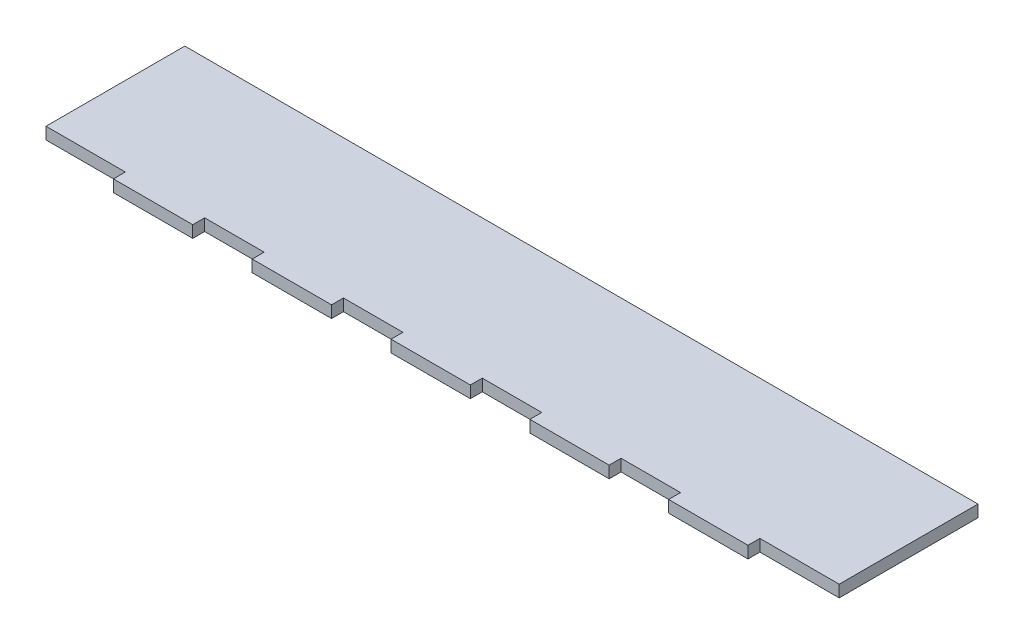
from build123d import *

# Parameters (mm, degrees)
BOSS_EXTRUDE1_DEPTH = 3


with BuildPart() as part:
    # Sketch1 → Boss-Extrude1 (new body)
    with BuildSketch(Plane(origin=(0, 0, 0), x_dir=(1, 0, 0), z_dir=(0, 1, 0))):
        Polygon((40, 0), (55, 0), (55, -3), (75, -3), (75, 0), (90, 0), (90, -3), (110, -3), (110, 0), (125, 0), (125, -3), (145, -3), (145, 0), (160, 0), (160, -3), (180, -3), (180, 0), (200, 0), (200, 35), (0, 35), (0, 0), (20, 0), (20, -3), (40, -3), align=None)
    extrude(amount=BOSS_EXTRUDE1_DEPTH)


solid = part.part
